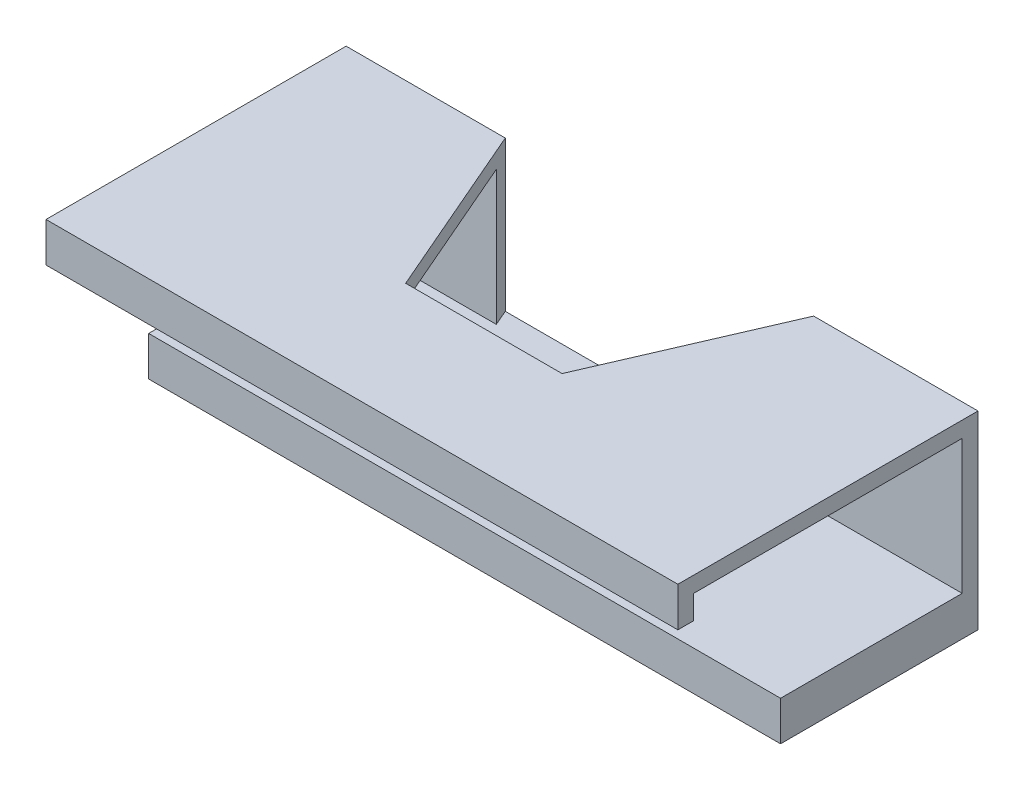
from build123d import *

# Parameters (mm, degrees)
SKETCH1_W           = 80
SKETCH1_H           = 25
BOSS_EXTRUDE1_DEPTH = 5
BOSS_EXTRUDE2_DEPTH = 80
CUT_EXTRUDE1_DEPTH  = 19


with BuildPart() as part:
    # Sketch1 → Boss-Extrude1 (new body)
    with BuildSketch(Plane(origin=(0, 0, 0), x_dir=(1, 0, 0), z_dir=(0, 1, 0))):
        with Locations((40, 12.5)):
            Rectangle(SKETCH1_W, SKETCH1_H)
    extrude(amount=BOSS_EXTRUDE1_DEPTH)

    # Sketch2 → Boss-Extrude2 (add)
    with BuildSketch(Plane.ZY):
        Polygon((-25, 5), (-25, 24), (13, 24), (13, 19), (11, 19), (11, 22), (-23, 22), (-23, 5), align=None)
    extrude(amount=-BOSS_EXTRUDE2_DEPTH)

    # Sketch3 → Cut-Extrude1 (cut)
    with BuildSketch(Plane(origin=(0, 24, 0), x_dir=(1, 0, 0), z_dir=(0, 1, 0))):
        Polygon((59.190693398, 25), (49.569343824, 2.768409055), (29.769781604, 2.768409055), (20.148432029, 25), align=None)
    extrude(amount=-CUT_EXTRUDE1_DEPTH, mode=Mode.SUBTRACT)


solid = part.part
